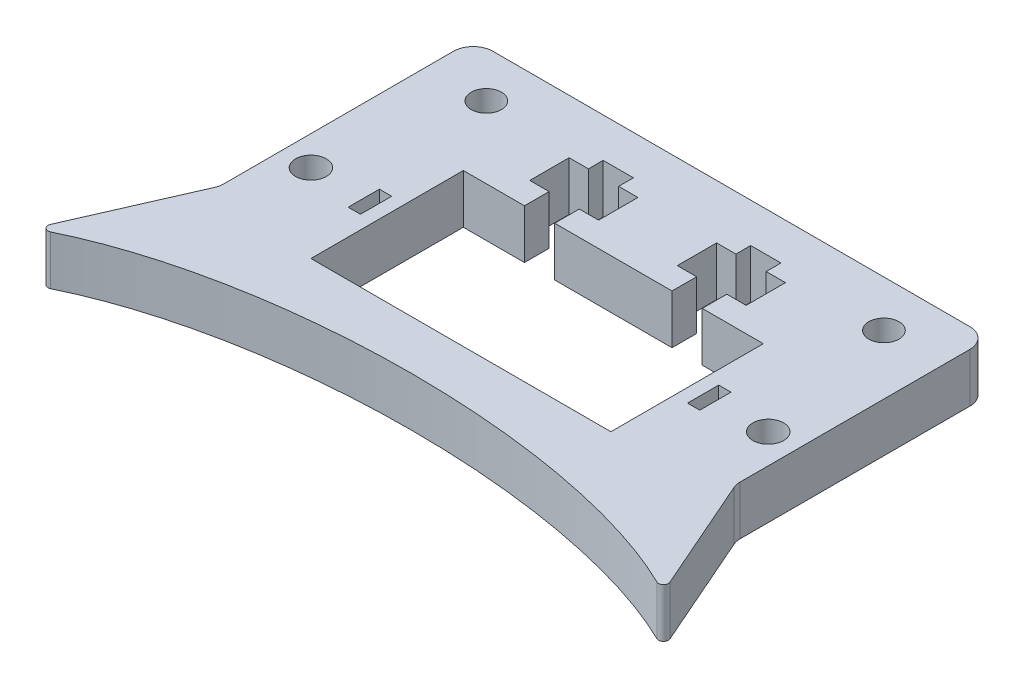
from build123d import *

# Parameters (mm, degrees)
SKETCH1_W           = 105
SKETCH1_H           = 65
BOSS_EXTRUDE1_DEPTH = 10
SKETCH2_W           = 61
SKETCH2_H           = 31
CUT_EXTRUDE1_DEPTH  = 11
SKETCH3_W           = 6.15
SKETCH3_H           = 5
SKETCH3_H_2         = 3
CUT_EXTRUDE2_DEPTH  = 10
SKETCH4_R           = 3.125
SKETCH4_W           = 2.5
SKETCH4_H           = 6.35
CUT_EXTRUDE3_DEPTH  = 11
BOSS_EXTRUDE2_DEPTH = 10
SKETCH6_R           = 3.075
CUT_EXTRUDE4_DEPTH  = 11.0000001
FILLET2_R           = 1
FILLET1_R           = 4


with BuildPart() as part:
    # Sketch1 → Boss-Extrude1 (new body)
    with BuildSketch(Plane(origin=(0, 0, 0), x_dir=(1, 0, 0), z_dir=(0, 1, 0))):
        Rectangle(SKETCH1_W, SKETCH1_H)
    extrude(amount=BOSS_EXTRUDE1_DEPTH)

    # Sketch2 → Cut-Extrude1 (cut, through all)
    with BuildSketch(Plane(origin=(0, 10, 0), x_dir=(1, 0, 0), z_dir=(0, 1, 0))):
        with Locations((0, -7)):
            Rectangle(SKETCH2_W, SKETCH2_H)
    extrude(amount=-CUT_EXTRUDE1_DEPTH, mode=Mode.SUBTRACT)

    # Sketch3 → Cut-Extrude2 (cut)
    with BuildSketch(Plane(origin=(0, 10, 0), x_dir=(1, 0, 0), z_dir=(0, 1, 0))):
        with Locations((-15, 11)):
            Rectangle(SKETCH3_W, SKETCH3_H)
        Polygon((-18.075, 21.5), (-22, 21.5), (-22, 13.5), (-18.075, 13.5), (-11.925, 13.5), (-8, 13.5), (-8, 21.5), (-11.925, 21.5), (-11.925, 18.5), (-18.075, 18.5), align=None)
        with Locations((-15, 20)):
            Rectangle(SKETCH3_W, SKETCH3_H_2)
        with Locations((-15, 23)):
            Rectangle(SKETCH3_W, SKETCH3_H_2)
    cut_extrude2 = extrude(amount=-CUT_EXTRUDE2_DEPTH, mode=Mode.SUBTRACT)

    # Sketch4 → Cut-Extrude3 (cut, through all)
    with BuildSketch(Plane(origin=(0, 10, 0), x_dir=(1, 0, 0), z_dir=(0, 1, 0))):
        with Locations((-46.5, -6.5)):
            Circle(SKETCH4_R)
        with Locations((-34.5, -6.5)):
            Rectangle(SKETCH4_W, SKETCH4_H)
    cut_extrude3 = extrude(amount=-CUT_EXTRUDE3_DEPTH, mode=Mode.SUBTRACT)

    # Sketch5 → Boss-Extrude2 (add)
    with BuildSketch(Plane(origin=(0, 0, 0), x_dir=(1, 0, 0), z_dir=(0, 1, 0))):
        with BuildLine():
            Line((0, -32.5), (-52.5, -19.039128985))
            Line((-52.5, -19.039128985), (-64.119998298, -45.565168911))
            add(Edge.make_bspline(
                [(0, -32.5), (-40.125285882, -32.5), (-64.119998298, -45.565168911)],
                knots=[4.71238898, 4.71238898, 4.71238898, 5.642188346, 5.642188346, 5.642188346], degree=2, weights=[1, 0.893866546, 1]))
        make_face()
    boss_extrude2 = extrude(amount=BOSS_EXTRUDE2_DEPTH)

    # Sketch6 → Cut-Extrude4 (cut, through all)
    with BuildSketch(Plane(origin=(0, 10, 0), x_dir=(1, 0, 0), z_dir=(0, 1, 0))):
        with Locations((-40.420875644, 23.095045258)):
            Circle(SKETCH6_R)
    cut_extrude4 = extrude(amount=-CUT_EXTRUDE4_DEPTH, mode=Mode.SUBTRACT)

    # Mirror1: Cut-Extrude2, Cut-Extrude3, Boss-Extrude2, Cut-Extrude4 across plane
    add(cut_extrude2.mirror(Plane(origin=(0, 0, 0), x_dir=(0, 0, 1), z_dir=(1, 0, 0))), mode=Mode.SUBTRACT)
    add(cut_extrude3.mirror(Plane(origin=(0, 0, 0), x_dir=(0, 0, 1), z_dir=(1, 0, 0))), mode=Mode.SUBTRACT)
    add(boss_extrude2.mirror(Plane(origin=(0, 0, 0), x_dir=(0, 0, 1), z_dir=(1, 0, 0))))
    add(cut_extrude4.mirror(Plane(origin=(0, 0, 0), x_dir=(0, 0, 1), z_dir=(1, 0, 0))), mode=Mode.SUBTRACT)

    # Fillet2
    fillet2_edges = [part.edges().sort_by_distance(p)[0] for p in [
        (-64.119998298, 5, 45.565168911),
        (64.119998298, 5, 45.565168911),
    ]]
    fillet(fillet2_edges, radius=FILLET2_R)

    # Fillet1
    fillet1_edges = [part.edges().sort_by_distance(p)[0] for p in [
        (52.5, 5, 19.039128985),
        (-52.5, 5, -32.5),
        (52.5, 5, -32.5),
        (-52.5, 5, 19.039128985),
    ]]
    fillet(fillet1_edges, radius=FILLET1_R)


solid = part.part
